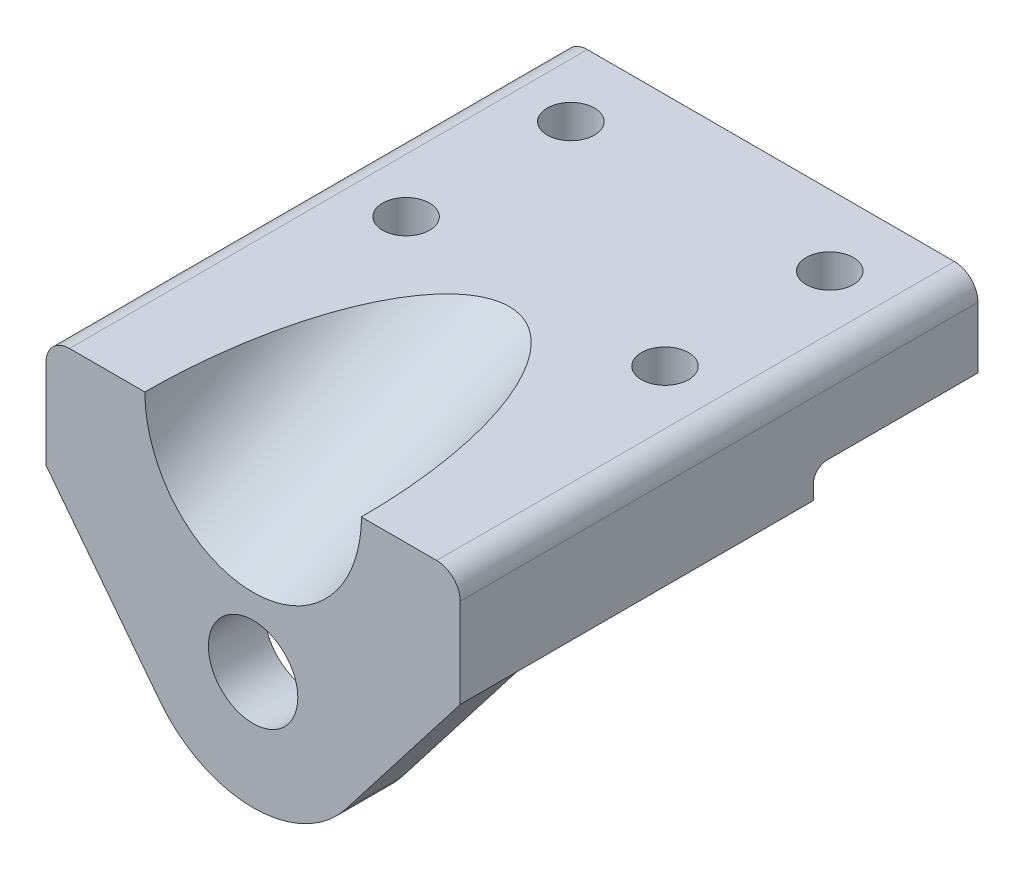
from build123d import *

# Parameters (mm, degrees)
SKETCH1_W               = 88
SKETCH1_H               = 110
SKETCH1_R               = 5
BOSS_EXTRUDE1_DEPTH     = 24
SKETCH3_R               = 9.5
BOSS_EXTRUDE2_DEPTH     = 12
FILLET1_R               = 5
SKETCH4_W               = 88
SKETCH4_H               = 6
CUT_EXTRUDE1_DEPTH      = 35
FILLET2_R               = 3
SKETCH5_R               = 23
CUT_EXTRUDE2_DEPTH      = 109
CUT_EXTRUDE2_DEPTH_BACK = 35


with BuildPart() as part:
    # Sketch1 → Boss-Extrude1 (new body)
    with BuildSketch(Plane(origin=(0, 0, 0), x_dir=(1, 0, 0), z_dir=(0, 1, 0))):
        with Locations((0, 55)):
            Rectangle(SKETCH1_W, SKETCH1_H)
        with Locations((-27.5, 95)):
            Circle(SKETCH1_R, mode=Mode.SUBTRACT)
        with Locations((-27.5, 60)):
            Circle(SKETCH1_R, mode=Mode.SUBTRACT)
        with Locations((27.5, 60)):
            Circle(SKETCH1_R, mode=Mode.SUBTRACT)
        with Locations((27.5, 95)):
            Circle(SKETCH1_R, mode=Mode.SUBTRACT)
    extrude(amount=-BOSS_EXTRUDE1_DEPTH)

    # Sketch3 → Boss-Extrude2 (add)
    with BuildSketch(Plane.XY):
        with BuildLine():
            Line((-44, -24), (-19.769224603, -55.302867659))
            ThreePointArc((-19.769224603, -55.302867659), (0, -65), (19.769224603, -55.302867659))
            Line((19.769224603, -55.302867659), (44, -24))
            Line((44, -24), (-44, -24))
        make_face()
        with Locations((0, -40)):
            Circle(SKETCH3_R, mode=Mode.SUBTRACT)
    extrude(amount=-BOSS_EXTRUDE2_DEPTH)

    # Fillet1
    fillet1_edges = [part.edges().sort_by_distance(p)[0] for p in [
        (-44, 0, -55),
        (44, 0, -55),
    ]]
    fillet(fillet1_edges, radius=FILLET1_R)

    # Sketch4 → Cut-Extrude1 (cut)
    with BuildSketch(Plane(origin=(0, 0, -110), x_dir=(-1, 0, 0), z_dir=(0, 0, -1))):
        with Locations((0, -21)):
            Rectangle(SKETCH4_W, SKETCH4_H)
    extrude(amount=-CUT_EXTRUDE1_DEPTH, mode=Mode.SUBTRACT)

    # Fillet2
    fillet2_edges = [part.edges().sort_by_distance(p)[0] for p in [
        (0, -18, -75),
    ]]
    fillet(fillet2_edges, radius=FILLET2_R)

    # Sketch5 → Cut-Extrude2 (cut, two sides)
    with BuildSketch(Plane(origin=(0, 0, 0), x_dir=(1, 0, 0), z_dir=(0, 0.422618262, -0.906307787))) as cut_extrude2_sk:
        Circle(SKETCH5_R)
    extrude(amount=CUT_EXTRUDE2_DEPTH, mode=Mode.SUBTRACT)
    extrude(cut_extrude2_sk.sketch, amount=-CUT_EXTRUDE2_DEPTH_BACK, mode=Mode.SUBTRACT)


solid = part.part
